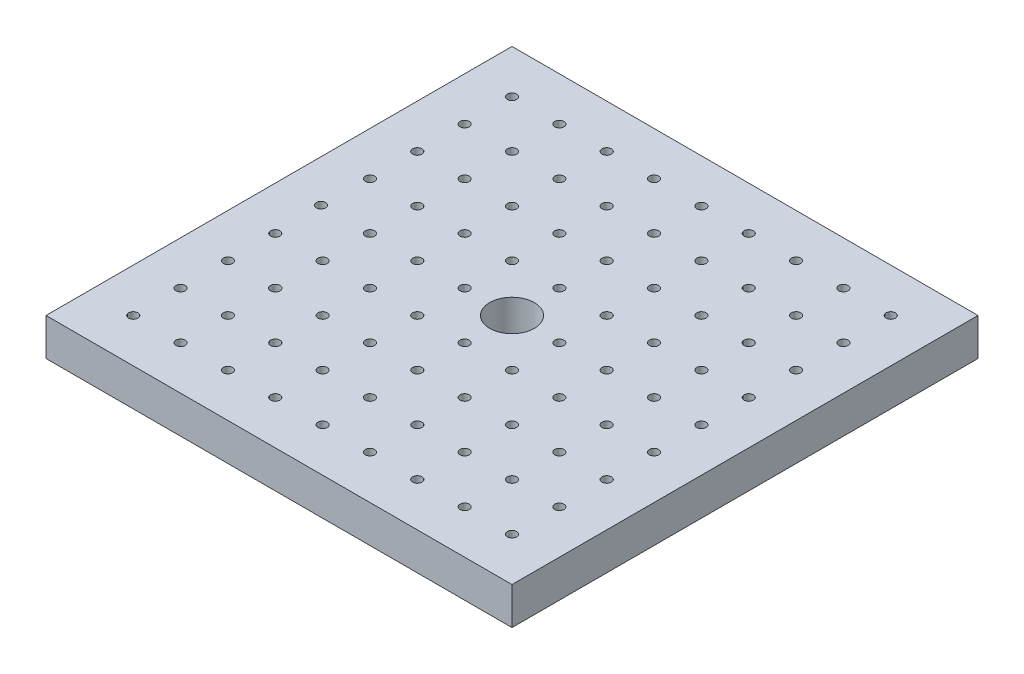
from build123d import *

# Parameters (mm, degrees)
SKETCH_1_W          = 25
SKETCH_1_H          = 25
EXTRUDE_1_DEPTH     = 2
SKETCH_2_R          = 1.2
CUT_EXTRUDE_1_DEPTH = 2
SKETCH_3_R          = 0.25
SKETCH_3_R_2        = 0.255
CUT_EXTRUDE_2_DEPTH = 2


with BuildPart() as part:
    # 스케치1 → 보스-돌출1 (new body)
    with BuildSketch(Plane(origin=(0, 0, 0), x_dir=(1, 0, 0), z_dir=(0, 1, 0))):
        Rectangle(SKETCH_1_W, SKETCH_1_H)
    extrude(amount=EXTRUDE_1_DEPTH)

    # 스케치2 → 컷-돌출1 (cut)
    with BuildSketch(Plane(origin=(0, 2, 0), x_dir=(1, 0, 0), z_dir=(0, 1, 0))):
        Circle(SKETCH_2_R)
    extrude(amount=-CUT_EXTRUDE_1_DEPTH, mode=Mode.SUBTRACT)

    # 스케치3 → 컷-돌출2 (cut)
    with BuildSketch(Plane(origin=(0, 2, 0), x_dir=(1, 0, 0), z_dir=(0, 1, 0))):
        Circle(SKETCH_3_R)
        with Locations((-2.54, 0)):
            Circle(SKETCH_3_R)
        with Locations((-5.08, 0)):
            Circle(SKETCH_3_R)
        with Locations((-7.62, 0)):
            Circle(SKETCH_3_R)
        with Locations((-10.24891396, 0)):
            Circle(SKETCH_3_R)
        with Locations((2.54, 0)):
            Circle(SKETCH_3_R)
        with Locations((5.08, 0)):
            Circle(SKETCH_3_R)
        with Locations((7.62, 0)):
            Circle(SKETCH_3_R)
        with Locations((10.16, 0)):
            Circle(SKETCH_3_R)
        with Locations((-10.16, 2.54)):
            Circle(SKETCH_3_R)
        with Locations((-7.62, 2.54)):
            Circle(SKETCH_3_R)
        with Locations((-5.08, 2.54)):
            Circle(SKETCH_3_R)
        with Locations((-2.54, 2.54)):
            Circle(SKETCH_3_R)
        with Locations((0, 2.54)):
            Circle(SKETCH_3_R)
        with Locations((2.54, 2.54)):
            Circle(SKETCH_3_R)
        with Locations((5.08, 2.54)):
            Circle(SKETCH_3_R)
        with Locations((7.62, 2.54)):
            Circle(SKETCH_3_R)
        with Locations((10.16, 2.54)):
            Circle(SKETCH_3_R)
        with Locations((-10.16, 5.08)):
            Circle(SKETCH_3_R)
        with Locations((-7.62, 5.08)):
            Circle(SKETCH_3_R)
        with Locations((-5.08, 5.08)):
            Circle(SKETCH_3_R)
        with Locations((-2.54, 5.08)):
            Circle(SKETCH_3_R)
        with Locations((0, 5.08)):
            Circle(SKETCH_3_R)
        with Locations((2.54, 5.08)):
            Circle(SKETCH_3_R)
        with Locations((5.08, 5.08)):
            Circle(SKETCH_3_R)
        with Locations((7.62, 5.08)):
            Circle(SKETCH_3_R)
        with Locations((10.16, 5.08)):
            Circle(SKETCH_3_R)
        with Locations((10.16, 7.62)):
            Circle(SKETCH_3_R)
        with Locations((7.62, 7.62)):
            Circle(SKETCH_3_R)
        with Locations((5.08, 7.62)):
            Circle(SKETCH_3_R)
        with Locations((2.54, 7.62)):
            Circle(SKETCH_3_R)
        with Locations((0, 7.62)):
            Circle(SKETCH_3_R)
        with Locations((-2.54, 7.62)):
            Circle(SKETCH_3_R)
        with Locations((-5.08, 7.62)):
            Circle(SKETCH_3_R)
        with Locations((-7.62, 7.62)):
            Circle(SKETCH_3_R)
        with Locations((-10.16, 7.62)):
            Circle(SKETCH_3_R)
        with Locations((10.16, 10.16)):
            Circle(SKETCH_3_R)
        with Locations((7.62, 10.16)):
            Circle(SKETCH_3_R)
        with Locations((5.08, 10.16)):
            Circle(SKETCH_3_R)
        with Locations((2.54, 10.16)):
            Circle(SKETCH_3_R)
        with Locations((0, 10.16)):
            Circle(SKETCH_3_R)
        with Locations((-2.54, 10.16)):
            Circle(SKETCH_3_R)
        with Locations((-5.08, 10.16)):
            Circle(SKETCH_3_R)
        with Locations((-7.62, 10.16)):
            Circle(SKETCH_3_R)
        with Locations((-10.16, 10.16)):
            Circle(SKETCH_3_R)
        with Locations((10.16, -2.54)):
            Circle(SKETCH_3_R)
        with Locations((7.62, -2.54)):
            Circle(SKETCH_3_R)
        with Locations((5.08, -2.54)):
            Circle(SKETCH_3_R)
        with Locations((2.54, -2.54)):
            Circle(SKETCH_3_R)
        with Locations((0, -2.54)):
            Circle(SKETCH_3_R)
        with Locations((-2.54, -2.54)):
            Circle(SKETCH_3_R)
        with Locations((-5.08, -2.54)):
            Circle(SKETCH_3_R)
        with Locations((-7.62, -2.54)):
            Circle(SKETCH_3_R)
        with Locations((-10.16, -2.54)):
            Circle(SKETCH_3_R)
        with Locations((10.16, -5.08)):
            Circle(SKETCH_3_R)
        with Locations((7.62, -5.08)):
            Circle(SKETCH_3_R)
        with Locations((5.08, -5.08)):
            Circle(SKETCH_3_R)
        with Locations((2.54, -5.08)):
            Circle(SKETCH_3_R)
        with Locations((0, -5.08)):
            Circle(SKETCH_3_R)
        with Locations((-2.54, -5.08)):
            Circle(SKETCH_3_R)
        with Locations((-5.08, -5.08)):
            Circle(SKETCH_3_R)
        with Locations((-7.62, -5.08)):
            Circle(SKETCH_3_R_2)
        with Locations((-10.16, -5.08)):
            Circle(SKETCH_3_R)
        with Locations((-10.16, -7.62)):
            Circle(SKETCH_3_R)
        with Locations((-7.62, -7.62)):
            Circle(SKETCH_3_R)
        with Locations((-5.08, -7.62)):
            Circle(SKETCH_3_R)
        with Locations((-2.54, -7.62)):
            Circle(SKETCH_3_R)
        with Locations((0, -7.62)):
            Circle(SKETCH_3_R)
        with Locations((2.54, -7.62)):
            Circle(SKETCH_3_R)
        with Locations((5.08, -7.62)):
            Circle(SKETCH_3_R)
        with Locations((7.62, -7.62)):
            Circle(SKETCH_3_R)
        with Locations((10.16, -7.62)):
            Circle(SKETCH_3_R)
        with Locations((-10.16, -10.16)):
            Circle(SKETCH_3_R)
        with Locations((-7.62, -10.16)):
            Circle(SKETCH_3_R)
        with Locations((-5.08, -10.16)):
            Circle(SKETCH_3_R)
        with Locations((-2.54, -10.16)):
            Circle(SKETCH_3_R)
        with Locations((0, -10.16)):
            Circle(SKETCH_3_R)
        with Locations((2.54, -10.16)):
            Circle(SKETCH_3_R)
        with Locations((5.08, -10.16)):
            Circle(SKETCH_3_R)
        with Locations((7.62, -10.16)):
            Circle(SKETCH_3_R)
        with Locations((10.16, -10.16)):
            Circle(SKETCH_3_R)
    extrude(amount=-CUT_EXTRUDE_2_DEPTH, mode=Mode.SUBTRACT)


solid = part.part
